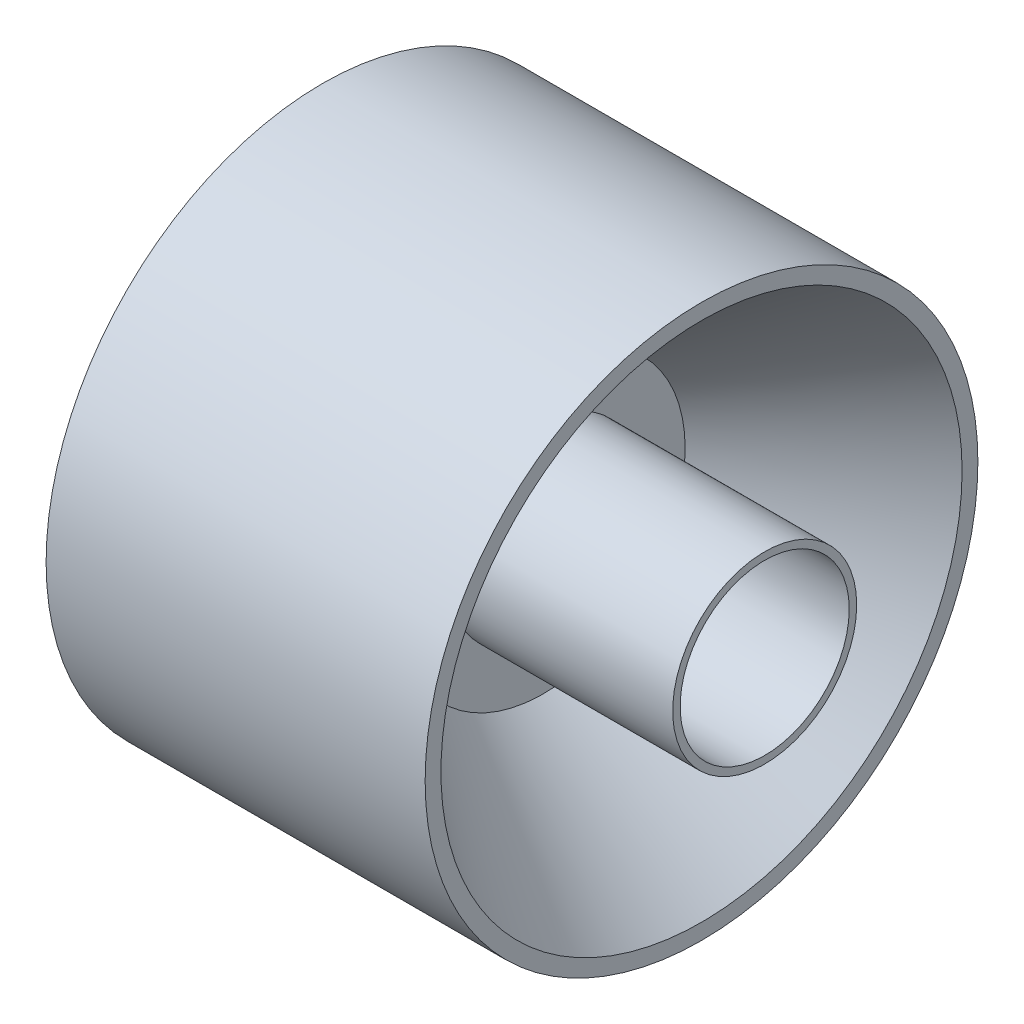
from build123d import *

# Parameters (mm, degrees)
SKETCH1_R           = 55.5625
BOSS_EXTRUDE1_DEPTH = 76.2
SKETCH2_R           = 52.3875
CUT_EXTRUDE1_DEPTH  = 31.75
CUT_EXTRUDE1_TAPER  = 37
SKETCH3_R           = 52.3875
CUT_EXTRUDE2_DEPTH  = 31.75
CUT_EXTRUDE2_TAPER  = 37
SKETCH4_R           = 18.5
SKETCH4_R_2         = 17
BOSS_EXTRUDE2_DEPTH = 44.45


with BuildPart() as part:
    # Sketch1 → Boss-Extrude1 (new body)
    with BuildSketch(Plane(origin=(0, 0, 0), x_dir=(0, 0, -1), z_dir=(1, 0, 0))):
        Circle(SKETCH1_R)
    extrude(amount=BOSS_EXTRUDE1_DEPTH)

    # Sketch2 → Cut-Extrude1 (cut)
    with BuildSketch(Plane(origin=(76.2, 0, 0), x_dir=(0, 0, -1), z_dir=(1, 0, 0))):
        Circle(SKETCH2_R)
    extrude(amount=-CUT_EXTRUDE1_DEPTH, taper=CUT_EXTRUDE1_TAPER, mode=Mode.SUBTRACT)

    # Sketch3 → Cut-Extrude2 (cut)
    with BuildSketch(Plane.ZY):
        Circle(SKETCH3_R)
    extrude(amount=-CUT_EXTRUDE2_DEPTH, taper=CUT_EXTRUDE2_TAPER, mode=Mode.SUBTRACT)

    # Sketch4 → Boss-Extrude2 (add)
    with BuildSketch(Plane(origin=(44.45, 0, 0), x_dir=(0, 0, -1), z_dir=(1, 0, 0))):
        Circle(SKETCH4_R)
        Circle(SKETCH4_R_2, mode=Mode.SUBTRACT)
    extrude(amount=BOSS_EXTRUDE2_DEPTH)


solid = part.part
